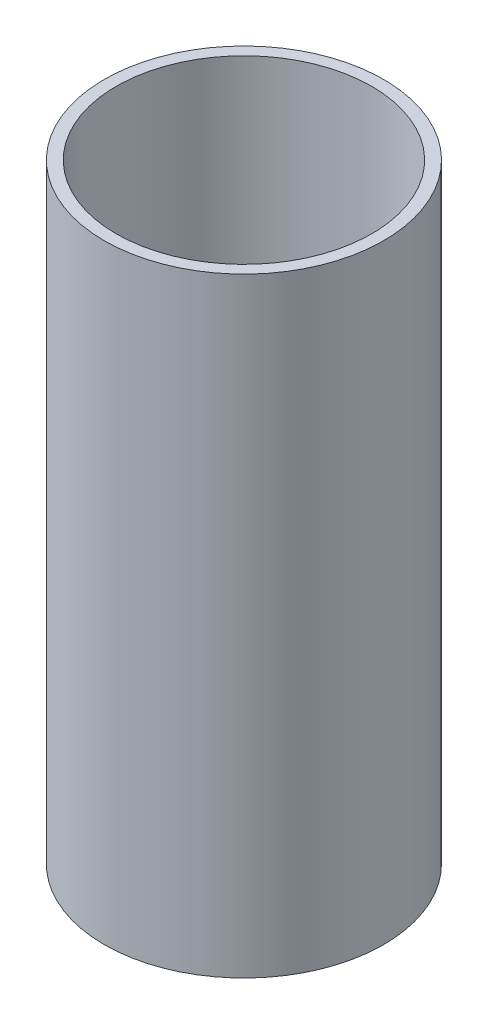
from build123d import *

# Parameters (mm, degrees)
SKETCH1_R           = 69.85
SKETCH1_R_2         = 63.881
BOSS_EXTRUDE1_DEPTH = 304.8


with BuildPart() as part:
    # Sketch1 → Boss-Extrude1 (new body)
    with BuildSketch(Plane(origin=(0, 0, 0), x_dir=(1, 0, 0), z_dir=(0, 1, 0))):
        Circle(SKETCH1_R)
        Circle(SKETCH1_R_2, mode=Mode.SUBTRACT)
    extrude(amount=BOSS_EXTRUDE1_DEPTH)


solid = part.part
